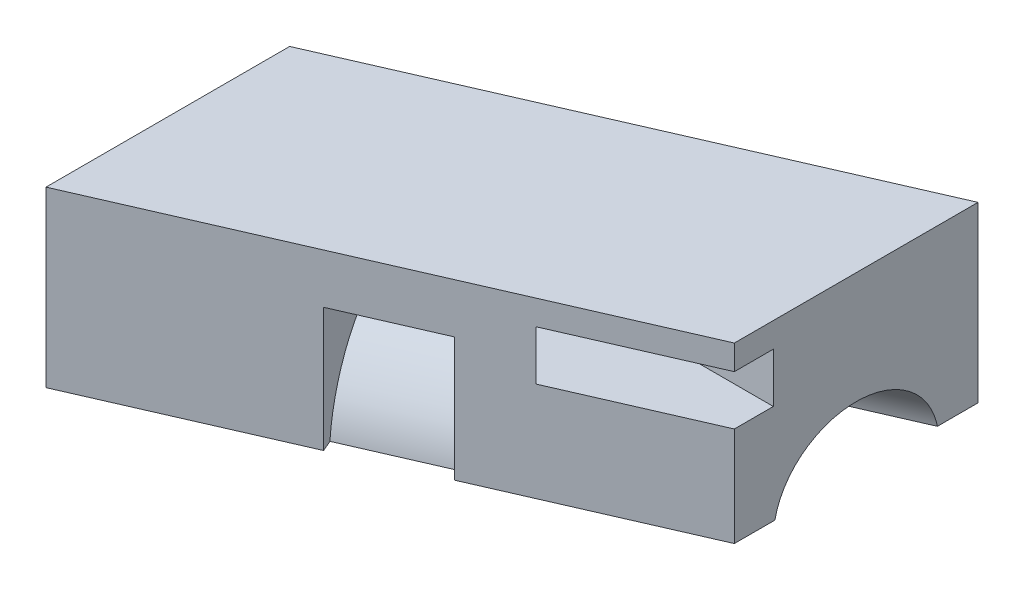
from build123d import *

# Parameters (mm, degrees)
BOSS_EXTRUDE2_DEPTH     = 7
CUT_EXTRUDE4_DEPTH      = 25
CUT_EXTRUDE7_DEPTH      = 4
SKETCH6_W               = 4
SKETCH6_H               = 2
CUT_EXTRUDE5_DEPTH      = 23.912878475
CUT_EXTRUDE5_DEPTH_BACK = 4.6
SKETCH12_W              = 3.6
SKETCH12_H              = 9.819805061
CUT_EXTRUDE10_DEPTH     = 8
SKETCH13_W              = 3.6
SKETCH13_H              = 9.819805061
CUT_EXTRUDE11_DEPTH     = 8


with BuildPart() as part:
    # Sketch2 → Boss-Extrude2 (new body)
    with BuildSketch(Plane(origin=(0, 0, 0), x_dir=(1, 0, 0), z_dir=(0, 1, 0))):
        Polygon((0, 0), (-3.6, 8.248636251), (19.312878475, 18.248636251), (22.912878475, 10), align=None)
    extrude(amount=BOSS_EXTRUDE2_DEPTH)

    # Sketch4 → Cut-Extrude4 (cut)
    with BuildSketch(Plane(origin=(0, 0, 0), x_dir=(0.4, 0, 0.916515139), z_dir=(-0.916515139, 0, 0.4))):
        with BuildLine():
            Line((-7.5, 7), (-1.5, 7))
            ThreePointArc((-1.5, 7), (-4.5, 4.5), (-7.5, 7))
        make_face()
    extrude(amount=-CUT_EXTRUDE4_DEPTH, mode=Mode.SUBTRACT)

    # Sketch8 → Cut-Extrude7 (cut)
    with BuildSketch(Plane(origin=(11.456439237, 0, -5), x_dir=(-0.4, 0, -0.916515139), z_dir=(0.916515139, 0, -0.4))):
        with BuildLine():
            Line((0.48751947, 7), (0, 7))
            Line((0, 7), (0, 2))
            Line((0, 2), (9, 2))
            Line((9, 2), (9, 7))
            Line((9, 7), (8.51248053, 7))
            ThreePointArc((8.51248053, 7), (4.5, 3.5), (0.48751947, 7))
        make_face()
    extrude(amount=-CUT_EXTRUDE7_DEPTH, mode=Mode.SUBTRACT)

    # Sketch6 → Cut-Extrude5 (cut, two sides)
    with BuildSketch(Plane(origin=(0, 0, 0), x_dir=(0, 0, -1), z_dir=(1, 0, 0))) as cut_extrude5_sk:
        with Locations((8, 2)):
            Rectangle(SKETCH6_W, SKETCH6_H)
    extrude(amount=CUT_EXTRUDE5_DEPTH, mode=Mode.SUBTRACT)
    extrude(cut_extrude5_sk.sketch, amount=-CUT_EXTRUDE5_DEPTH_BACK, mode=Mode.SUBTRACT)

    # Sketch12 → Cut-Extrude10 (cut, through all)
    with BuildSketch(Plane(origin=(0, 0, 0), x_dir=(1, 0, 0), z_dir=(0, 1, 0))):
        with Locations((21.112878475, 13.338733721)):
            Rectangle(SKETCH12_W, SKETCH12_H)
    extrude(amount=CUT_EXTRUDE10_DEPTH, mode=Mode.SUBTRACT)

    # Sketch13 → Cut-Extrude11 (cut, through all)
    with BuildSketch(Plane(origin=(0, 0, 0), x_dir=(1, 0, 0), z_dir=(0, 1, 0))):
        with Locations((-1.8, 4.909902531)):
            Rectangle(SKETCH13_W, SKETCH13_H)
    extrude(amount=CUT_EXTRUDE11_DEPTH, mode=Mode.SUBTRACT)


with BuildPart() as body_2:
    # Mirror9: mirrored copy
    add(part.part.mirror(Plane(origin=(0, 0, 0), x_dir=(0, 0, 1), z_dir=(0, -1, 0))))


solid = body_2.part
